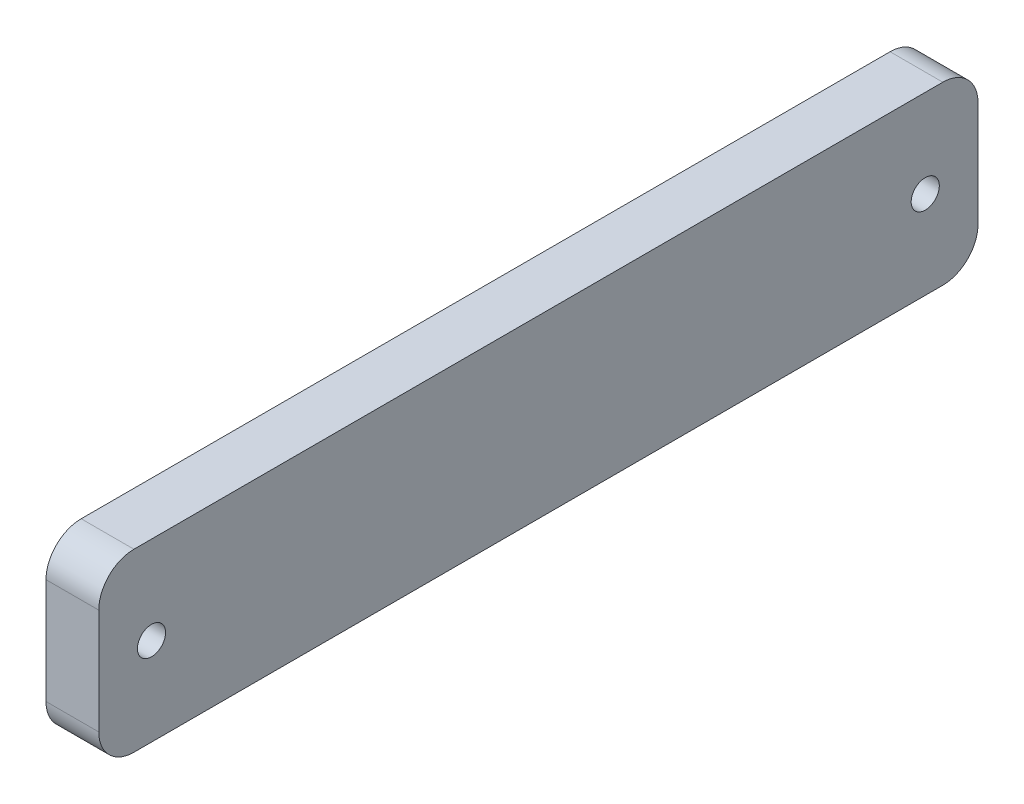
from build123d import *

# Parameters (mm, degrees)
ESBO_O1_W                = 50
ESBO_O1_H                = 10
ESBO_O1_R                = 0.8
RESSALTO_EXTRUS_O1_DEPTH = 3
FILETE1_R                = 2


with BuildPart() as part:
    # Esboço1 → Ressalto-extrusão1 (new body)
    with BuildSketch(Plane(origin=(0, 0, 0), x_dir=(0, 0, -1), z_dir=(1, 0, 0))):
        Rectangle(ESBO_O1_W, ESBO_O1_H)
        with Locations((-22, 0)):
            Circle(ESBO_O1_R, mode=Mode.SUBTRACT)
        with Locations((22, 0)):
            Circle(ESBO_O1_R, mode=Mode.SUBTRACT)
    extrude(amount=RESSALTO_EXTRUS_O1_DEPTH)

    # Filete1
    filete1_edges = [part.edges().sort_by_distance(p)[0] for p in [
        (1.5, -5, -25),
        (1.5, -5, 25),
        (1.5, 5, 25),
        (1.5, 5, -25),
    ]]
    fillet(filete1_edges, radius=FILETE1_R)


solid = part.part
